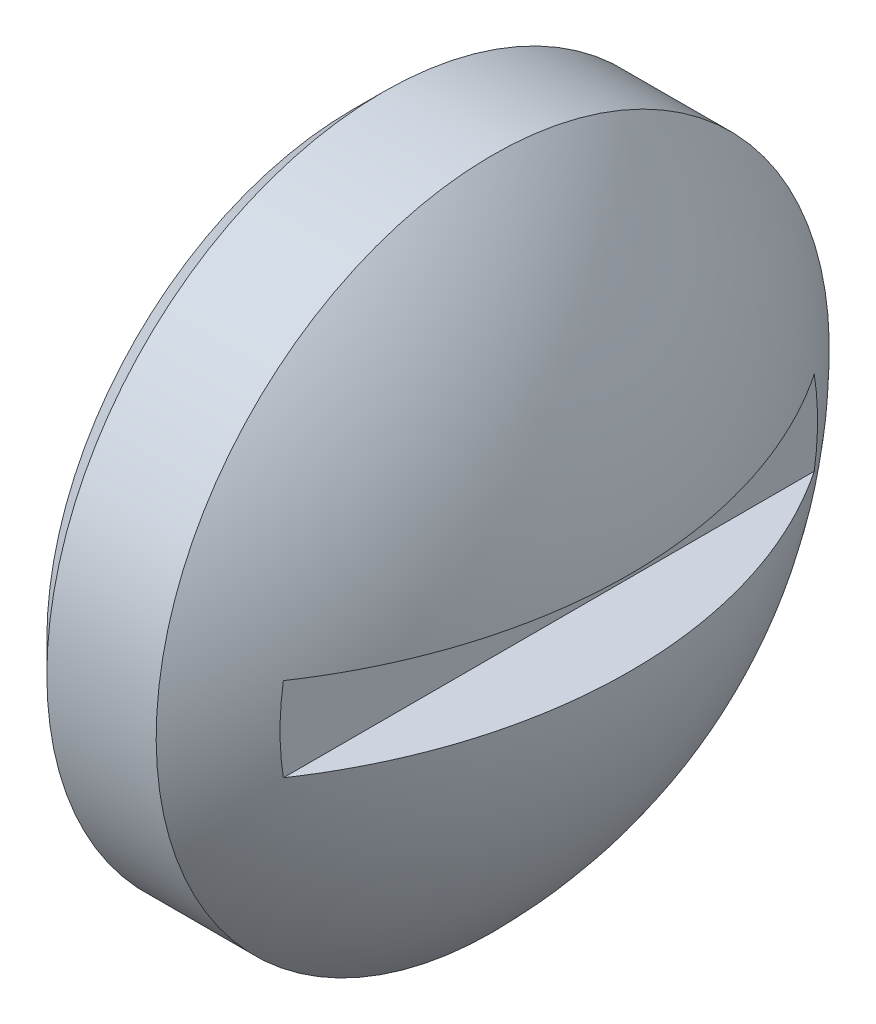
from build123d import *

# Parameters (mm, degrees)
CHAMFER_1_SIZE      = 1.1015
SKETCH_2_W          = 50
SKETCH_2_H          = 3
CUT_EXTRUDE_1_DEPTH = 3.892099643


with BuildPart() as part:
    # Эскиз1 → Повернуть1 (revolve)
    with BuildSketch(Plane.XY):
        with BuildLine():
            Line((0, 12), (5, 12))
            ThreePointArc((5, 12), (8.36795896, 7.179530606), (9.892099643, 1.5))
            Line((9.892099643, 1.5), (7, 1.5))
            Line((7, 1.5), (7, 0))
            Line((7, 0), (3.5, 0))
            Line((3.5, 0), (3.5, 7.5))
            Line((3.5, 7.5), (0, 7.5))
            Line((0, 7.5), (0, 12))
        make_face()
    revolve(axis=Axis((0, 0, 0), (1, 0, 0)))

    # Фаска1
    chamfer_1_edges = [part.edges().sort_by_distance(p)[0] for p in [
        (0, -12, 0),
    ]]
    chamfer(chamfer_1_edges, length=CHAMFER_1_SIZE)

    # Эскиз2 → Вырез-Вытянуть1 (cut, through all)
    with BuildSketch(Plane(origin=(7, 0, 0), x_dir=(0, 0, -1), z_dir=(1, 0, 0))):
        Rectangle(SKETCH_2_W, SKETCH_2_H)
    extrude(amount=CUT_EXTRUDE_1_DEPTH, mode=Mode.SUBTRACT)


solid = part.part
